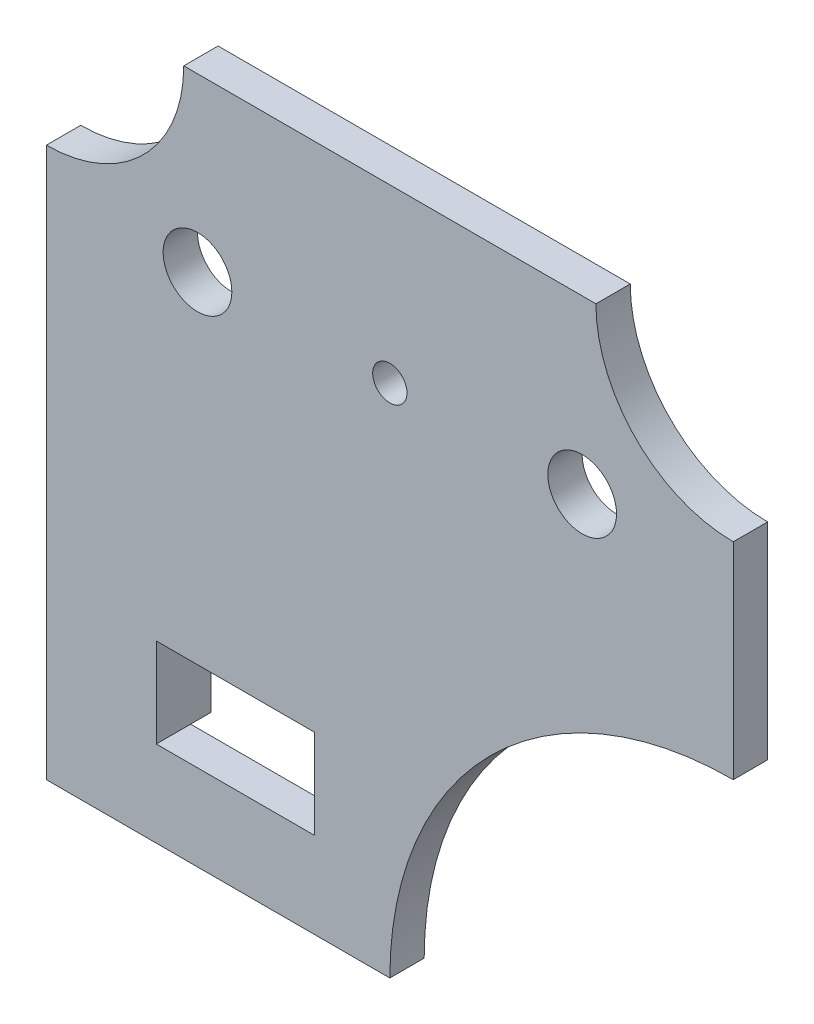
from build123d import *

# Parameters (mm, degrees)
CROQUIS1_R              = 2.5
CROQUIS1_R_2            = 5
CROQUIS1_W              = 23
CROQUIS1_H              = 13
SALIENTE_EXTRUIR1_DEPTH = 2.5
CROQUIS2_W              = 4.5
CROQUIS2_H              = 13
SALIENTE_EXTRUIR2_DEPTH = 8


with BuildPart() as part:
    # Croquis1 → Saliente-Extruir1 (new body, symmetric)
    with BuildSketch(Plane.XY):
        with BuildLine():
            Line((30, 25), (-30, 25))
            ThreePointArc((-30, 25), (-35.857864376, 10.857864376), (-50, 5))
            Line((-50, 5), (-50, -75))
            Line((-50, -75), (0, -75))
            ThreePointArc((0, -75), (14.644660941, -39.644660941), (50, -25))
            Line((50, -25), (50, 5))
            ThreePointArc((50, 5), (35.857864376, 10.857864376), (30, 25))
        make_face()
        Circle(CROQUIS1_R, mode=Mode.SUBTRACT)
        with Locations((-28, 0)):
            Circle(CROQUIS1_R_2, mode=Mode.SUBTRACT)
        with Locations((28, 0)):
            Circle(CROQUIS1_R_2, mode=Mode.SUBTRACT)
        with Locations((-22.5, -56)):
            Rectangle(CROQUIS1_W, CROQUIS1_H, mode=Mode.SUBTRACT)
    extrude(amount=SALIENTE_EXTRUIR1_DEPTH, both=True)

    # Croquis2 → Saliente-Extruir2 (add)
    with BuildSketch(Plane.XY.offset(2.5)):
        with Locations((-36.25, -56)):
            Rectangle(CROQUIS2_W, CROQUIS2_H)
        with Locations((-8.75, -56)):
            Rectangle(CROQUIS2_W, CROQUIS2_H)
    extrude(amount=-SALIENTE_EXTRUIR2_DEPTH)


solid = part.part
